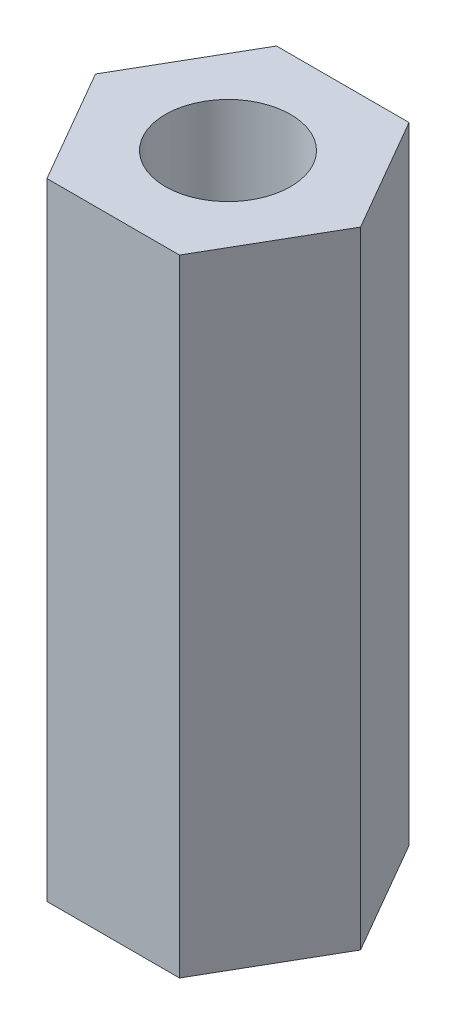
from build123d import *

# Parameters (mm, degrees)
SKETCH1_R           = 1.5
BOSS_EXTRUDE1_DEPTH = 15


with BuildPart() as part:
    # Sketch1 → Boss-Extrude1 (new body)
    with BuildSketch(Plane(origin=(0, 0, 0), x_dir=(1, 0, 0), z_dir=(0, 1, 0))):
        Polygon((-1.58771324, 2.75), (-3.175426481, 0), (-1.58771324, -2.75), (1.58771324, -2.75), (3.175426481, 0), (1.58771324, 2.75), align=None)
        Circle(SKETCH1_R, mode=Mode.SUBTRACT)
    extrude(amount=BOSS_EXTRUDE1_DEPTH)


solid = part.part
